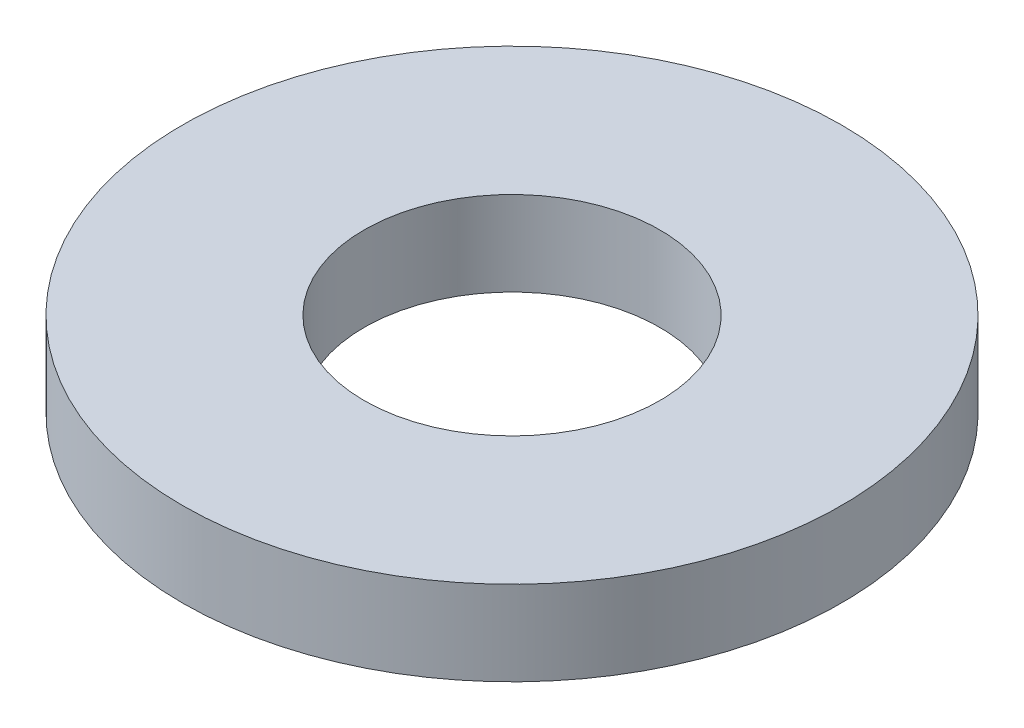
from build123d import *

# Parameters (mm, degrees)
SKETCH1_R           = 3.9624
BOSS_EXTRUDE1_DEPTH = 1.016
SKETCH5_R           = 1.778
CUT_EXTRUDE1_DEPTH  = 2.016


with BuildPart() as part:
    # Sketch1 → Boss-Extrude1 (new body)
    with BuildSketch(Plane(origin=(0, 0, 0), x_dir=(1, 0, 0), z_dir=(0, 1, 0))):
        Circle(SKETCH1_R)
    extrude(amount=BOSS_EXTRUDE1_DEPTH)

    # Sketch5 → Cut-Extrude1 (cut, through all)
    with BuildSketch(Plane(origin=(0, 1.016, 0), x_dir=(-1, 0, 0), z_dir=(0, 1, 0))):
        Circle(SKETCH5_R)
    extrude(amount=-CUT_EXTRUDE1_DEPTH, mode=Mode.SUBTRACT)


solid = part.part
